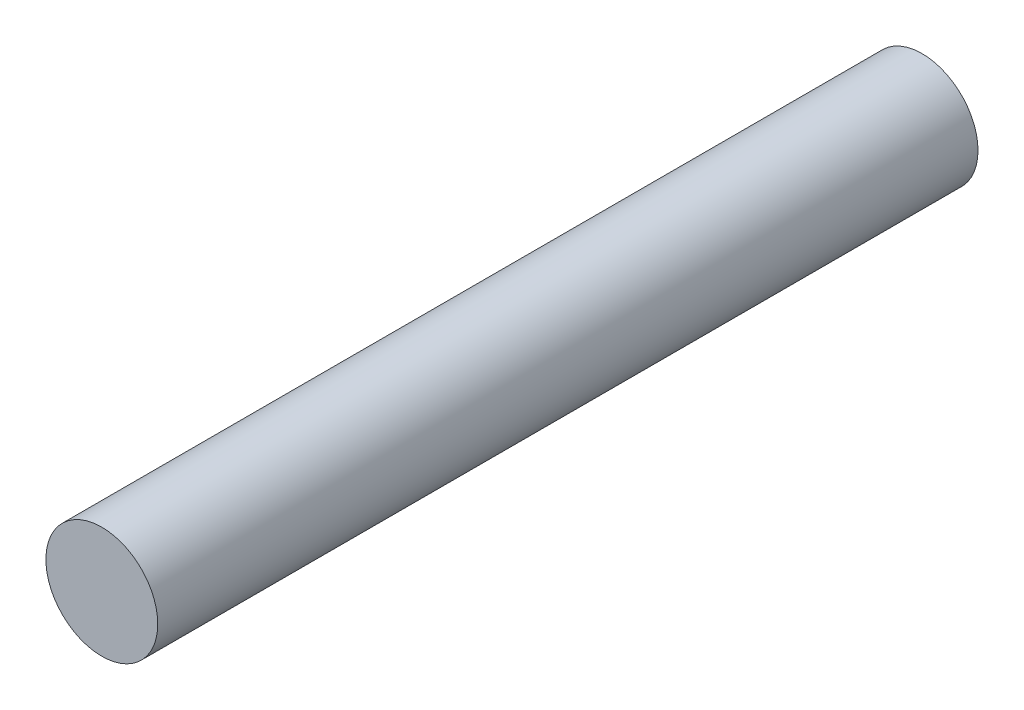
from build123d import *

# Parameters (mm, degrees)
SKETCH1_R           = 3.75
BOSS_EXTRUDE1_DEPTH = 27.5


with BuildPart() as part:
    # Sketch1 → Boss-Extrude1 (new body, symmetric)
    with BuildSketch(Plane.XY):
        Circle(SKETCH1_R)
    extrude(amount=BOSS_EXTRUDE1_DEPTH, both=True)


solid = part.part
